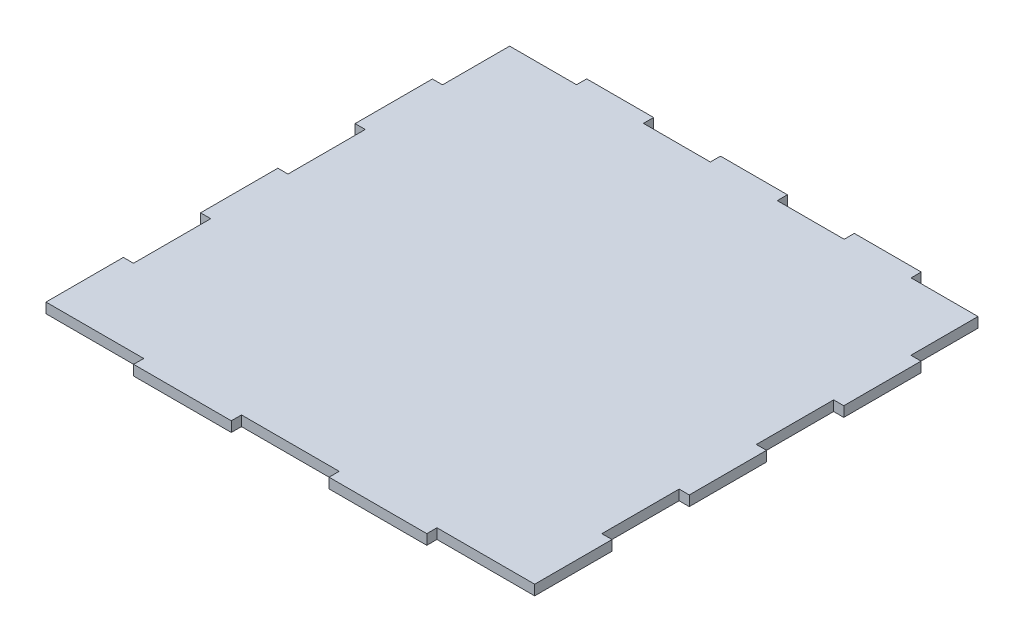
from build123d import *

# Parameters (mm, degrees)
BOSS_EXTRUDE1_DEPTH = 3
SKETCH2_W           = 138.4
SKETCH2_H           = 3
CUT_EXTRUDE1_DEPTH  = 4
SKETCH3_W           = 19.771429
SKETCH3_H           = 3
BOSS_EXTRUDE2_DEPTH = 3


with BuildPart() as part:
    # Sketch1 → Boss-Extrude1 (new body)
    with BuildSketch(Plane(origin=(0, 0, 0), x_dir=(1, 0, 0), z_dir=(0, 1, 0))):
        Polygon((0, 0), (28.88, 0), (28.88, -3), (57.76, -3), (57.76, 0), (86.64, 0), (86.64, -3), (115.52, -3), (115.52, 0), (144.4, 0), (144.4, 22.85), (141.4, 22.85), (141.4, 45.68), (144.4, 45.68), (144.4, 68.51), (141.4, 68.51), (141.4, 91.34), (144.4, 91.34), (144.4, 114.17), (141.4, 114.17), (141.4, 137), (3, 137), (3, 114.17), (0, 114.17), (0, 91.34), (3, 91.34), (3, 68.51), (0, 68.51), (0, 45.68), (3, 45.68), (3, 22.85), (0, 22.85), align=None)
    extrude(amount=BOSS_EXTRUDE1_DEPTH)

    # Sketch2 → Cut-Extrude1 (cut, through all)
    with BuildSketch(Plane.XZ):
        with Locations((72.2, -135.5)):
            Rectangle(SKETCH2_W, SKETCH2_H)
    extrude(amount=-CUT_EXTRUDE1_DEPTH, mode=Mode.SUBTRACT)

    # Sketch3 → Boss-Extrude2 (add)
    with BuildSketch(Plane.XZ):
        with Locations((32.657143071, -135.5)):
            Rectangle(SKETCH3_W, SKETCH3_H)
        with Locations((72.200001071, -135.5)):
            Rectangle(SKETCH3_W, SKETCH3_H)
        with Locations((111.742859071, -135.5)):
            Rectangle(SKETCH3_W, SKETCH3_H)
    extrude(amount=-BOSS_EXTRUDE2_DEPTH)


solid = part.part
